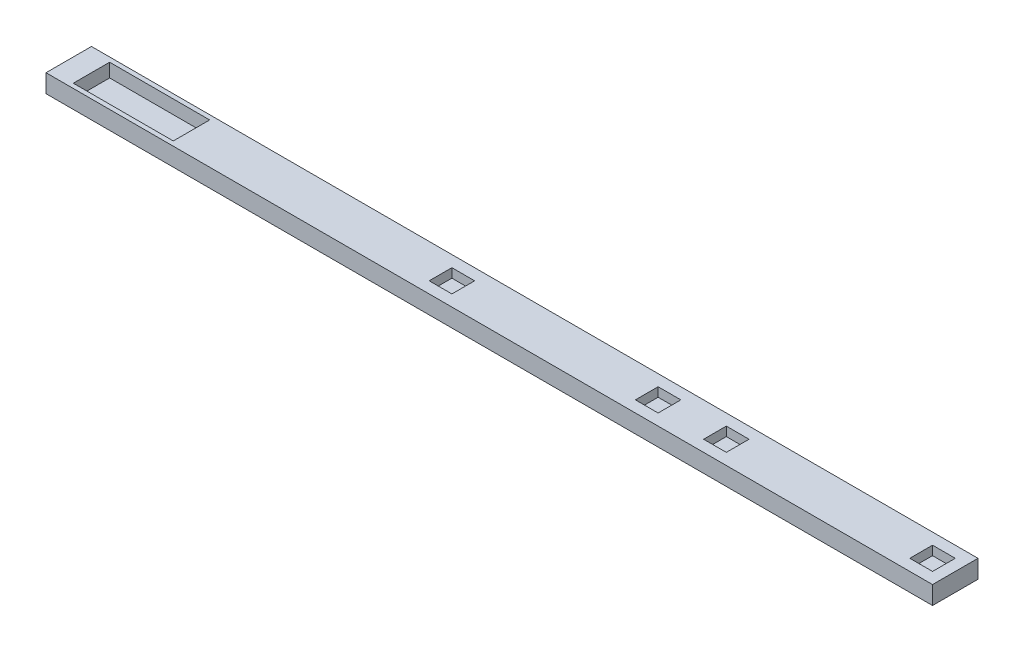
from build123d import *

# Parameters (mm, degrees)
SKETCH_1_W          = 195
SKETCH_1_H          = 10
EXTRUDE_1_DEPTH     = 4
SKETCH_2_W          = 22
SKETCH_2_H          = 8
CUT_EXTRUDE_1_DEPTH = 3
SKETCH_3_W          = 5
SKETCH_3_H          = 5
CUT_EXTRUDE_2_DEPTH = 2


with BuildPart() as part:
    # 草图1 → 凸台-拉伸1 (new body)
    with BuildSketch(Plane(origin=(0, 0, 0), x_dir=(1, 0, 0), z_dir=(0, 1, 0))):
        Rectangle(SKETCH_1_W, SKETCH_1_H)
    extrude(amount=EXTRUDE_1_DEPTH)

    # 草图2 → 切除-拉伸1 (cut)
    with BuildSketch(Plane(origin=(0, 4, 0), x_dir=(1, 0, 0), z_dir=(0, 1, 0))):
        with Locations((-81.5, 0)):
            Rectangle(SKETCH_2_W, SKETCH_2_H)
    extrude(amount=-CUT_EXTRUDE_1_DEPTH, mode=Mode.SUBTRACT)

    # 草图3 → 切除-拉伸2 (cut)
    with BuildSketch(Plane(origin=(0, 4, 0), x_dir=(1, 0, 0), z_dir=(0, 1, 0))):
        with Locations((92.5, 0)):
            Rectangle(SKETCH_3_W, SKETCH_3_H)
        with Locations((47.14, 0)):
            Rectangle(SKETCH_3_W, SKETCH_3_H)
        with Locations((-13.22, 0)):
            Rectangle(SKETCH_3_W, SKETCH_3_H)
        with Locations((32.14, 0)):
            Rectangle(SKETCH_3_W, SKETCH_3_H)
    extrude(amount=-CUT_EXTRUDE_2_DEPTH, mode=Mode.SUBTRACT)


solid = part.part
